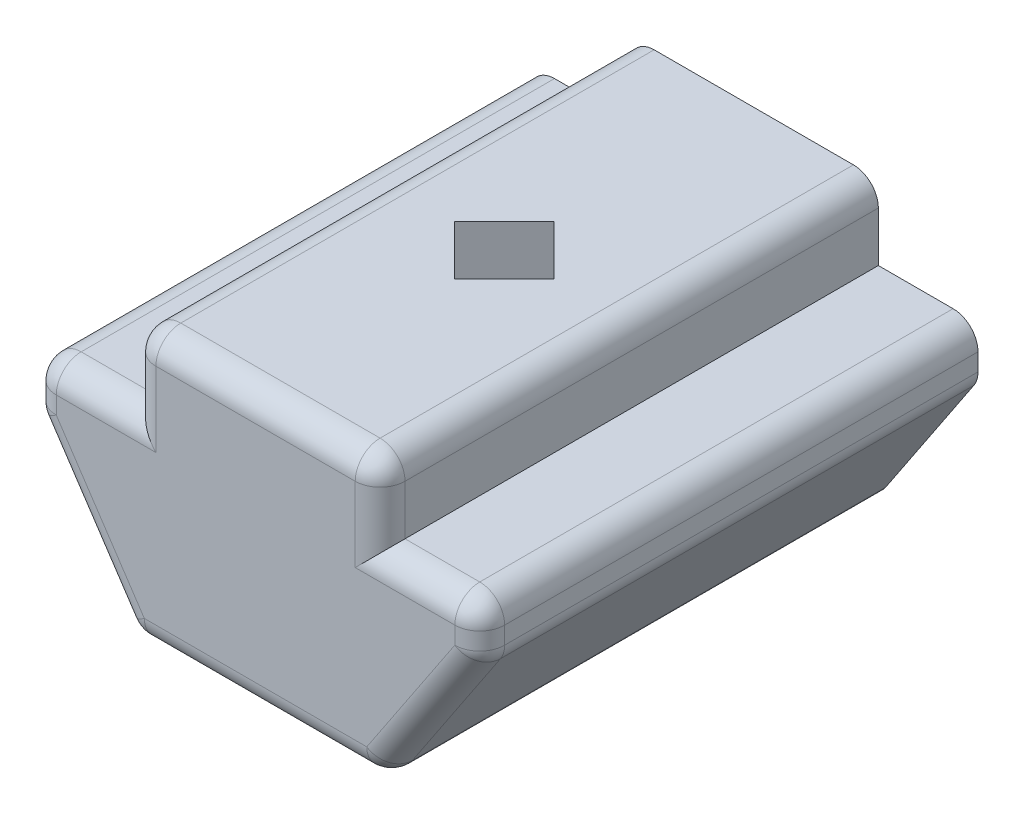
from build123d import *

# Parameters (mm, degrees)
BOSS_EXTRUDE1_DEPTH = 10
CUT_EXTRUDE2_DEPTH  = 6.5
FILLET1_R           = 0.5
FILLET2_R           = 0.5


with BuildPart() as part:
    # Sketch1 → Boss-Extrude1 (new body)
    with BuildSketch(Plane.XY):
        Polygon((-2.5, -4.047619048), (2.5, -4.047619048), (4.5, -1.047619048), (4.5, -0.047619048), (2.5, -0.047619048), (2.5, 1.452380952), (-2.5, 1.452380952), (-2.5, -0.047619048), (-4.5, -0.047619048), (-4.5, -1.047619048), align=None)
    extrude(amount=BOSS_EXTRUDE1_DEPTH)

    # Sketch4 → Cut-Extrude2 (cut, through all)
    with BuildSketch(Plane(origin=(0, 1.452380952, 0), x_dir=(1, 0, 0), z_dir=(0, 1, 0))):
        Polygon((-1.021105314, -4.986458601), (-0.021105314, -3.986458601), (0.978894686, -4.986458601), (-0.021105314, -5.986458601), align=None)
    extrude(amount=-CUT_EXTRUDE2_DEPTH, mode=Mode.SUBTRACT)

    # Fillet1
    fillet1_edges = [part.edges().sort_by_distance(p)[0] for p in [
        (2.5, -4.047619048, 5),
        (-2.5, -4.047619048, 5),
        (-4.5, -1.047619048, 5),
        (-4.5, -0.047619048, 5),
        (-2.5, 1.452380952, 5),
        (2.5, 1.452380952, 5),
        (4.5, -0.047619048, 5),
        (4.5, -1.047619048, 5),
    ]]
    fillet(fillet1_edges, radius=FILLET1_R)

    # Fillet2
    fillet2_edges = [part.edges().sort_by_distance(p)[0] for p in [
        (2.5, 0.452380952, 10),
        (-3.25, -0.047619048, 10),
        (3.532229208, -2.499275236, 10),
        (0, -4.047619048, 10),
        (4.5, -0.721925138, 10),
        (3.25, -0.047619048, 10),
        (0, 1.452380952, 10),
        (-2.5, 0.452380952, 10),
        (-4.5, -0.721925138, 10),
        (-3.532229208, -2.499275236, 10),
        (-2.353553391, 1.305934343, 10),
        (-4.353553391, -0.194065657, 10),
        (-4.478546013, -1.041123303, 10),
        (2.353553391, 1.305934343, 10),
        (4.353553391, -0.194065657, 10),
        (4.478546013, -1.041123303, 10),
        (-2.468337084, -3.988456347, 10),
        (2.468337084, -3.988456347, 10),
    ]]
    fillet(fillet2_edges, radius=FILLET2_R)


solid = part.part
